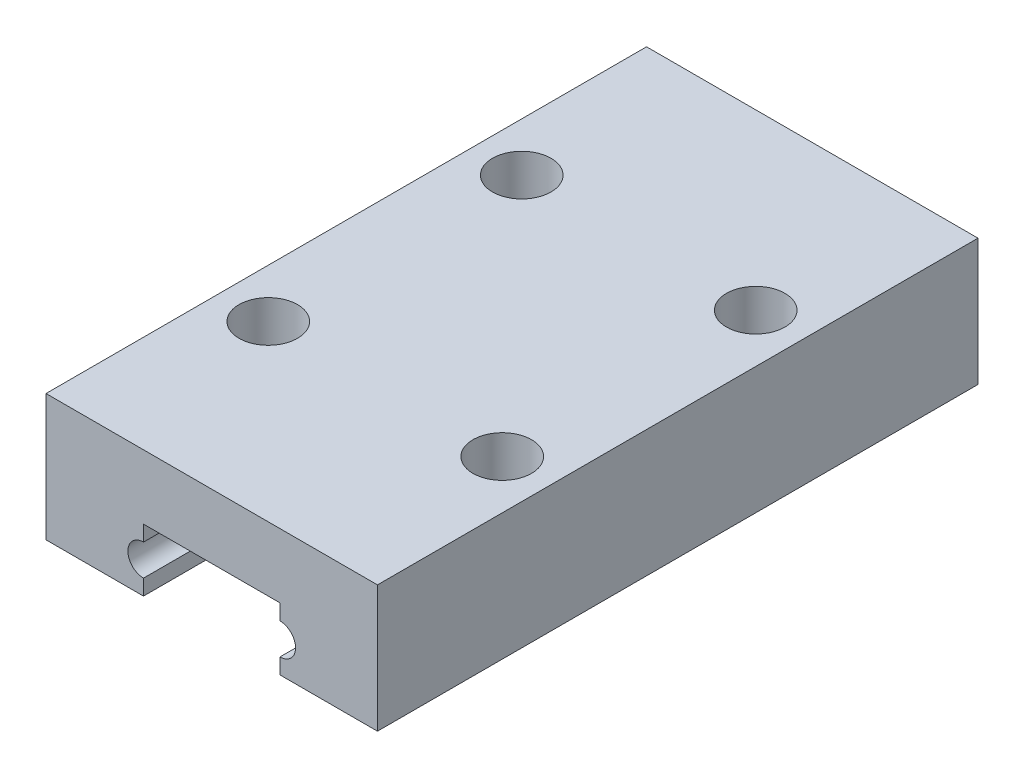
from build123d import *

# Parameters (mm, degrees)
RESSALTO_EXTRUS_O1_DEPTH = 30.8
ESBO_O2_R                = 1.5
CORTE_EXTRUS_O1_DEPTH    = 30.8


with BuildPart() as part:
    # Esboço1 → Ressalto-extrusão1 (new body)
    with BuildSketch(Plane.XY):
        with BuildLine():
            Line((-8.5, 6.5), (8.5, 6.5))
            Line((8.5, 6.5), (8.5, 0))
            Line((8.5, 0), (3.5, 0))
            Line((3.5, 0), (3.5, 0.8))
            ThreePointArc((3.5, 0.8), (4.3, 1.6), (3.5, 2.4))
            Line((3.5, 2.4), (3.5, 3.2))
            Line((3.5, 3.2), (-3.5, 3.2))
            Line((-3.5, 3.2), (-3.5, 2.4))
            ThreePointArc((-3.5, 2.4), (-4.3, 1.6), (-3.5, 0.8))
            Line((-3.5, 0.8), (-3.5, 0))
            Line((-3.5, 0), (-8.5, 0))
            Line((-8.5, 0), (-8.5, 6.5))
        make_face()
    extrude(amount=RESSALTO_EXTRUS_O1_DEPTH)

    # Esboço2 → Corte-extrusão1 (cut)
    with BuildSketch(Plane(origin=(0, 6.5, 0), x_dir=(1, 0, 0), z_dir=(0, 1, 0))):
        with Locations((6, -21.9)):
            Circle(ESBO_O2_R)
        with Locations((6, -8.9)):
            Circle(ESBO_O2_R)
        with Locations((-6, -21.9)):
            Circle(ESBO_O2_R)
        with Locations((-6, -8.9)):
            Circle(ESBO_O2_R)
    extrude(amount=-CORTE_EXTRUS_O1_DEPTH, mode=Mode.SUBTRACT)


solid = part.part
